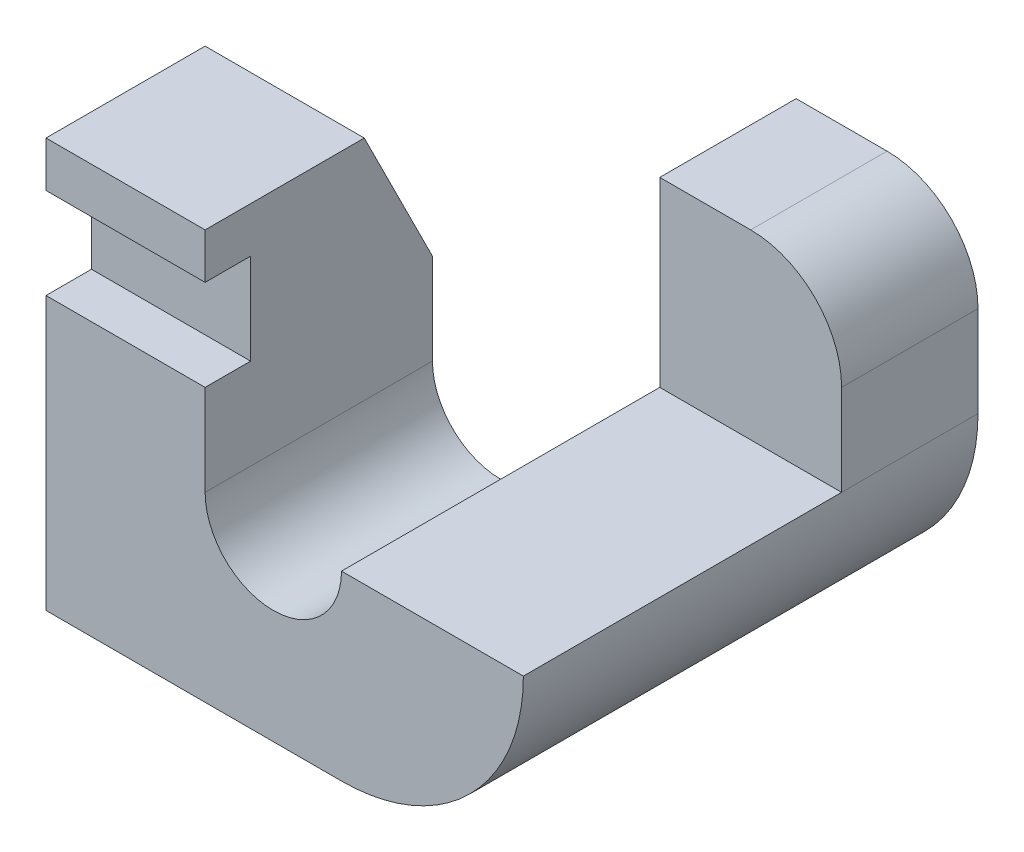
from build123d import *

# Parameters (mm, degrees)
BOSS_EXTRUDE1_DEPTH = 80
SKETCH2_W           = 56
SKETCH2_H           = 40
CUT_EXTRUDE1_DEPTH  = 32
SKETCH3_W           = 52
SKETCH3_H           = 40
CUT_EXTRUDE2_DEPTH  = 100
CUT_EXTRUDE3_DEPTH  = 100
SKETCH5_W           = 8
SKETCH5_H           = 16
CUT_EXTRUDE4_DEPTH  = 100


with BuildPart() as part:
    # Sketch1 → Boss-Extrude1 (new body)
    with BuildSketch(Plane.XY):
        with BuildLine():
            Line((-64.034777708, 29.634699451), (-36.034777708, 29.634699451))
            Line((-36.034777708, 29.634699451), (-36.034777708, -10.365300549))
            ThreePointArc((-36.034777708, -10.365300549), (-24.034777708, -22.365300549), (-12.034777708, -10.365300549))
            Line((-12.034777708, -10.365300549), (-12.034777708, 21.634699451))
            Line((-12.034777708, 21.634699451), (3.965222292, 21.634699451))
            ThreePointArc((3.965222292, 21.634699451), (15.278930791, 16.94840795), (19.965222292, 5.634699451))
            Line((19.965222292, 5.634699451), (19.965222292, -10.365300549))
            ThreePointArc((19.965222292, -10.365300549), (10.59263929, -32.992717547), (-12.034777708, -42.365300549))
            Line((-12.034777708, -42.365300549), (-64.034777708, -42.365300549))
            Line((-64.034777708, -42.365300549), (-64.034777708, 29.634699451))
        make_face()
    extrude(amount=BOSS_EXTRUDE1_DEPTH)

    # Sketch2 → Cut-Extrude1 (cut)
    with BuildSketch(Plane(origin=(19.965222292, 0, 0), x_dir=(0, 0, -1), z_dir=(1, 0, 0))):
        with Locations((-52, 9.634699451)):
            Rectangle(SKETCH2_W, SKETCH2_H)
    extrude(amount=-CUT_EXTRUDE1_DEPTH, mode=Mode.SUBTRACT)

    # Sketch3 → Cut-Extrude2 (cut)
    with BuildSketch(Plane(origin=(0, 29.634699451, 0), x_dir=(1, 0, 0), z_dir=(0, 1, 0))):
        with Locations((-38.034777708, -20)):
            Rectangle(SKETCH3_W, SKETCH3_H)
    extrude(amount=-CUT_EXTRUDE2_DEPTH, mode=Mode.SUBTRACT)

    # Sketch4 → Cut-Extrude3 (cut)
    with BuildSketch(Plane(origin=(-36.034777708, 0, 0), x_dir=(0, 0, -1), z_dir=(1, 0, 0))):
        Polygon((-40, 29.634699451), (-40, 5.634699451), (-52, 29.634699451), align=None)
    extrude(amount=-CUT_EXTRUDE3_DEPTH, mode=Mode.SUBTRACT)

    # Sketch5 → Cut-Extrude4 (cut)
    with BuildSketch(Plane(origin=(0, 0, 0), x_dir=(0, 0, -1), z_dir=(1, 0, 0))):
        with Locations((-76, 13.634699451)):
            Rectangle(SKETCH5_W, SKETCH5_H)
    extrude(amount=-CUT_EXTRUDE4_DEPTH, mode=Mode.SUBTRACT)


solid = part.part
